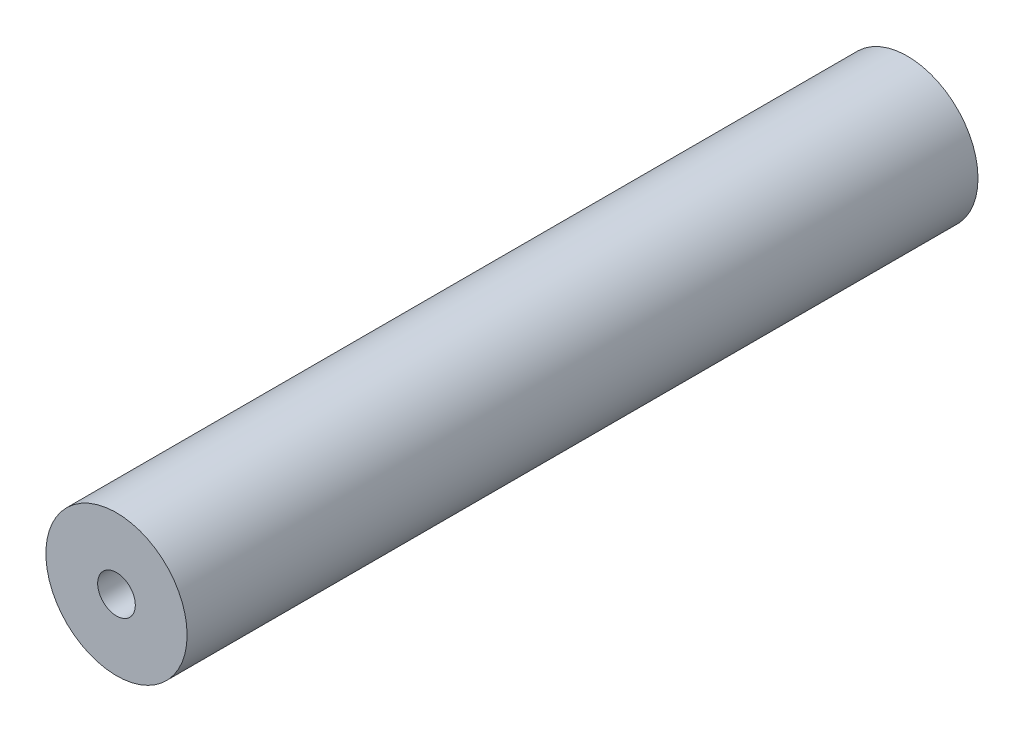
from build123d import *

# Parameters (mm, degrees)
SKETCH1_R           = 9.375
BOSS_EXTRUDE1_DEPTH = 105
SKETCH4_R           = 2.5
CUT_EXTRUDE1_DEPTH  = 20


with BuildPart() as part:
    # Sketch1 → Boss-Extrude1 (new body)
    with BuildSketch(Plane.XY):
        Circle(SKETCH1_R)
    extrude(amount=BOSS_EXTRUDE1_DEPTH)

    # Sketch4 → Cut-Extrude1 (cut)
    with BuildSketch(Plane.XY.offset(105)):
        Circle(SKETCH4_R)
    cut_extrude1 = extrude(amount=-CUT_EXTRUDE1_DEPTH, mode=Mode.SUBTRACT)

    # Mirror1: Cut-Extrude1 across plane
    add(cut_extrude1.mirror(Plane(origin=(0, 0, 52.5), x_dir=(1, 0, 0), z_dir=(0, 0, -1))), mode=Mode.SUBTRACT)


solid = part.part
